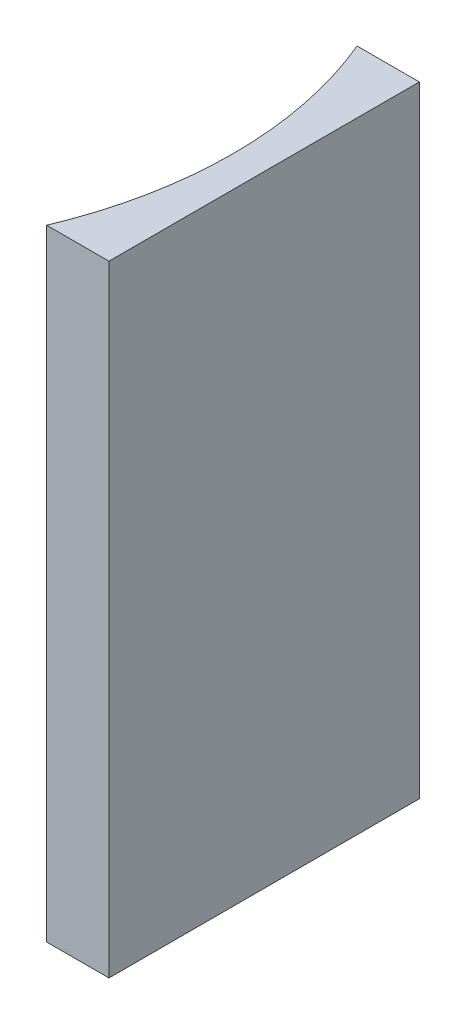
from build123d import *

# Parameters (mm, degrees)
EXTRUDE_1_DEPTH = 40


with BuildPart() as part:
    # 草图1 → 凸台-拉伸1 (new body)
    with BuildSketch(Plane(origin=(0, 0, 0), x_dir=(1, 0, 0), z_dir=(0, 1, 0))):
        with BuildLine():
            Line((0, 0), (0, -20))
            Line((0, -20), (-4.012581935, -20))
            ThreePointArc((-4.012581935, -20), (-2, -10), (-4.012581935, 0))
            Line((-4.012581935, 0), (0, 0))
        make_face()
    extrude(amount=EXTRUDE_1_DEPTH)


solid = part.part
